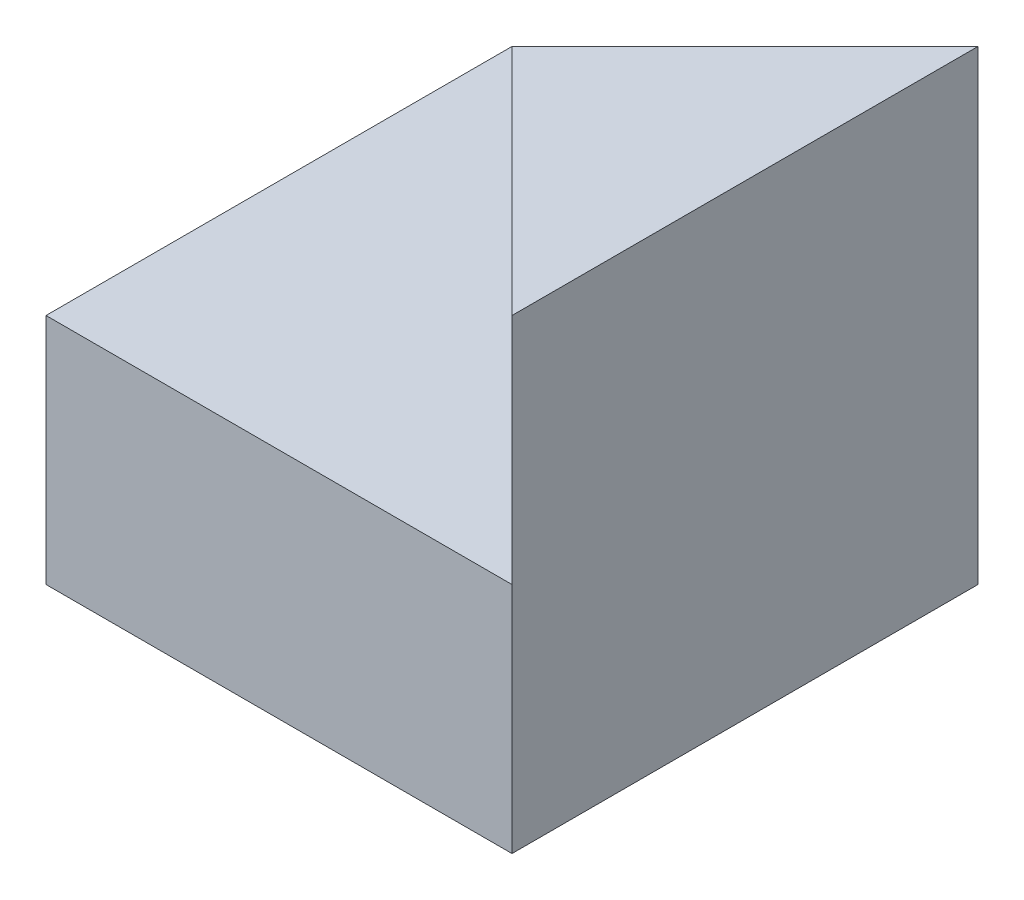
from build123d import *

# Parameters (mm, degrees)
SKETCH1_W           = 40
SKETCH1_H           = 20
BOSS_EXTRUDE1_DEPTH = 40
SKETCH2_W           = 20
SKETCH2_H           = 20
BOSS_EXTRUDE2_DEPTH = 40
CUT_EXTRUDE1_DEPTH  = 20


with BuildPart() as part:
    # Sketch1 → Boss-Extrude1 (new body)
    with BuildSketch(Plane.XY):
        with Locations((20, 10)):
            Rectangle(SKETCH1_W, SKETCH1_H)
    extrude(amount=BOSS_EXTRUDE1_DEPTH)

    # Sketch2 → Boss-Extrude2 (add)
    with BuildSketch(Plane.XY.offset(40)):
        with Locations((30, 30)):
            Rectangle(SKETCH2_W, SKETCH2_H)
    extrude(amount=-BOSS_EXTRUDE2_DEPTH)

    # Sketch3 → Cut-Extrude1 (cut)
    with BuildSketch(Plane(origin=(0, 40, 0), x_dir=(1, 0, 0), z_dir=(0, 1, 0))):
        Polygon((20, 0), (20, -20), (40, 0), align=None)
        Polygon((40, -40), (20, -20), (20, -40), align=None)
    extrude(amount=-CUT_EXTRUDE1_DEPTH, mode=Mode.SUBTRACT)


solid = part.part
